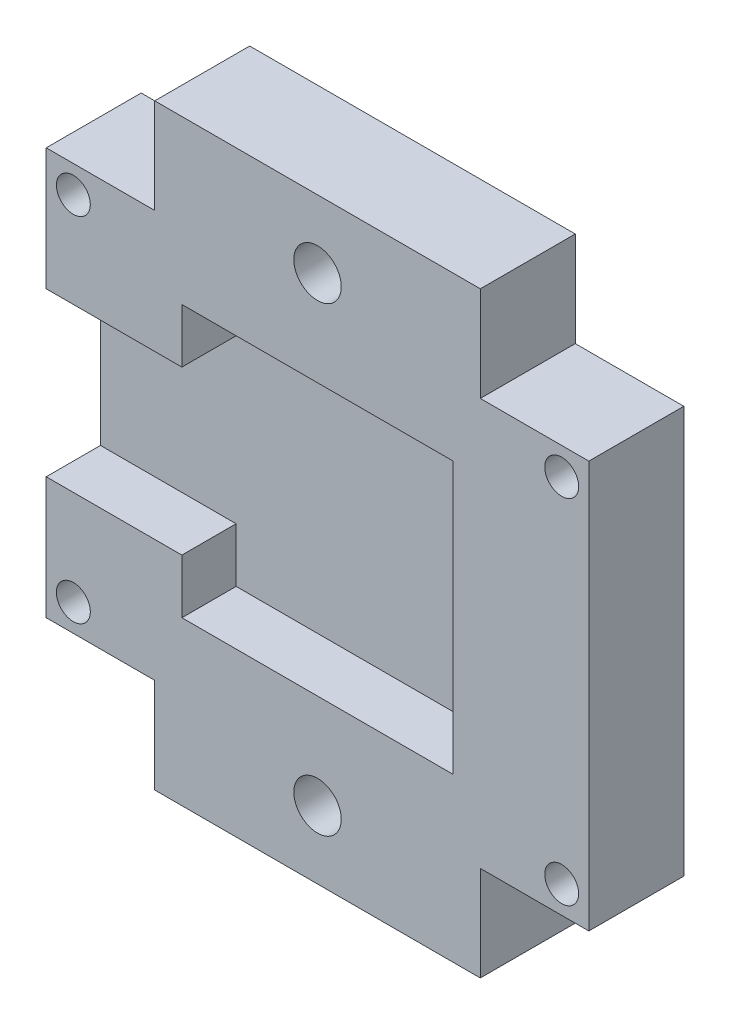
from build123d import *

# Parameters (mm, degrees)
SKETCH1_W           = 40
SKETCH1_H           = 30
BOSS_EXTRUDE1_DEPTH = 7
SKETCH2_W           = 20
SKETCH2_H           = 20
CUT_EXTRUDE1_DEPTH  = 4
SKETCH3_W           = 4
SKETCH3_H           = 12
CUT_EXTRUDE2_DEPTH  = 26
SKETCH4_R           = 1.25
CUT_EXTRUDE3_DEPTH  = 8
SKETCH5_W           = 24
SKETCH5_H           = 7
BOSS_EXTRUDE2_DEPTH = 7
SKETCH6_R           = 1.75
CUT_EXTRUDE4_DEPTH  = 8


with BuildPart() as part:
    # Sketch1 → Boss-Extrude1 (new body)
    with BuildSketch(Plane.XY):
        with Locations((20, 15)):
            Rectangle(SKETCH1_W, SKETCH1_H)
    extrude(amount=BOSS_EXTRUDE1_DEPTH)

    # Sketch2 → Cut-Extrude1 (cut)
    with BuildSketch(Plane.XY.offset(7)):
        with Locations((20, 15)):
            Rectangle(SKETCH2_W, SKETCH2_H)
    extrude(amount=-CUT_EXTRUDE1_DEPTH, mode=Mode.SUBTRACT)

    # Sketch3 → Cut-Extrude2 (cut)
    with BuildSketch(Plane.ZY):
        with Locations((5, 15)):
            Rectangle(SKETCH3_W, SKETCH3_H)
    extrude(amount=-CUT_EXTRUDE2_DEPTH, mode=Mode.SUBTRACT)

    # Sketch4 → Cut-Extrude3 (cut, through all)
    with BuildSketch(Plane.XY.offset(7)):
        with Locations((2, 28)):
            Circle(SKETCH4_R)
        with Locations((38, 28)):
            Circle(SKETCH4_R)
        with Locations((38, 2)):
            Circle(SKETCH4_R)
        with Locations((2, 2)):
            Circle(SKETCH4_R)
    extrude(amount=-CUT_EXTRUDE3_DEPTH, mode=Mode.SUBTRACT)

    # Sketch5 → Boss-Extrude2 (add)
    with BuildSketch(Plane.XY.offset(7)):
        with Locations((20, 33.5)):
            Rectangle(SKETCH5_W, SKETCH5_H)
        with Locations((20, -3.5)):
            Rectangle(SKETCH5_W, SKETCH5_H)
    extrude(amount=-BOSS_EXTRUDE2_DEPTH)

    # Sketch6 → Cut-Extrude4 (cut, through all)
    with BuildSketch(Plane.XY.offset(7)):
        with Locations((20, -2)):
            Circle(SKETCH6_R)
        with Locations((20, 32)):
            Circle(SKETCH6_R)
    extrude(amount=-CUT_EXTRUDE4_DEPTH, mode=Mode.SUBTRACT)


solid = part.part
